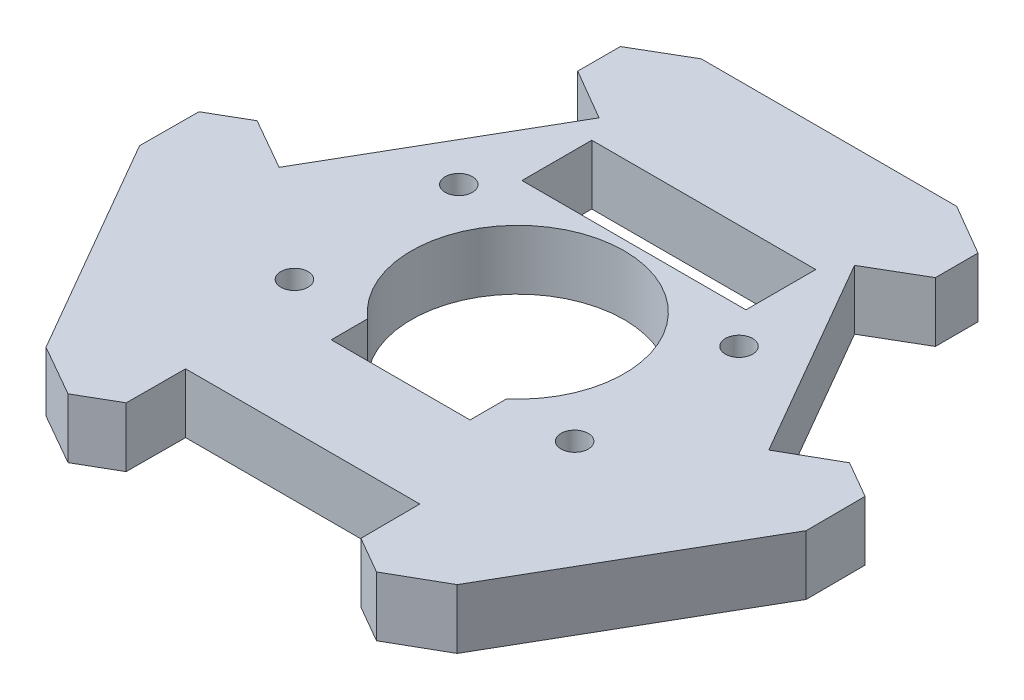
from build123d import *

# Parameters (mm, degrees)
BOSS_EXTRUDE3_DEPTH = 7
SKETCH2_R           = 1.6
SKETCH2_W           = 26.3
SKETCH2_H           = 8.2
CUT_EXTRUDE1_DEPTH  = 8


with BuildPart() as part:
    # Sketch1 → Boss-Extrude3 (new body)
    with BuildSketch(Plane(origin=(0, 0, 0), x_dir=(1, 0, 0), z_dir=(0, 1, 0))):
        Polygon((29.1090159, -7.44261314), (29.140104813, -0.496460718), (42.890104813, -0.496460718), (56.640104813, -0.496460718), (56.671193726, -7.44261314), (61.001320745, -9.94261314), (67.032409659, -6.496460718), (82.032409659, 19.484301396), (82.001320745, 26.430453819), (77.671193726, 28.930453819), (71.640104813, 25.484301396), (64.765104813, 37.392150698), (57.890104813, 49.3), (63.890104813, 52.8), (63.890104813, 57.8), (57.890104813, 61.3), (27.890104813, 61.3), (21.890104813, 57.8), (21.890104813, 52.8), (27.890104813, 49.3), (21.015104813, 37.392150698), (14.140104813, 25.484301396), (8.1090159, 28.930453819), (3.778888881, 26.430453819), (3.747799968, 19.484301396), (18.747799968, -6.496460718), (24.778888881, -9.94261314), align=None)
    extrude(amount=BOSS_EXTRUDE3_DEPTH)

    # Sketch2 → Cut-Extrude1 (cut, through all)
    with BuildSketch(Plane(origin=(0, 7, 0), x_dir=(1, 0, 0), z_dir=(0, 1, 0))):
        with Locations((59.342544079, 34.284301396)):
            Circle(SKETCH2_R)
        with Locations((59.342544079, 14.984301396)):
            Circle(SKETCH2_R)
        with Locations((26.437665547, 14.984301396)):
            Circle(SKETCH2_R)
        with Locations((26.437665547, 34.284301396)):
            Circle(SKETCH2_R)
        with BuildLine():
            Line((34.740104813, 11.003539282), (51.040104813, 11.003539282))
            Line((51.040104813, 11.003539282), (51.040104813, 15.284876488))
            ThreePointArc((51.040104813, 15.284876488), (42.890104813, 37.262613559), (34.740104813, 15.284876488))
            Line((34.740104813, 15.284876488), (34.740104813, 11.003539282))
        make_face()
        with Locations((42.890104813, 42.5)):
            Rectangle(SKETCH2_W, SKETCH2_H)
    extrude(amount=-CUT_EXTRUDE1_DEPTH, mode=Mode.SUBTRACT)


solid = part.part
